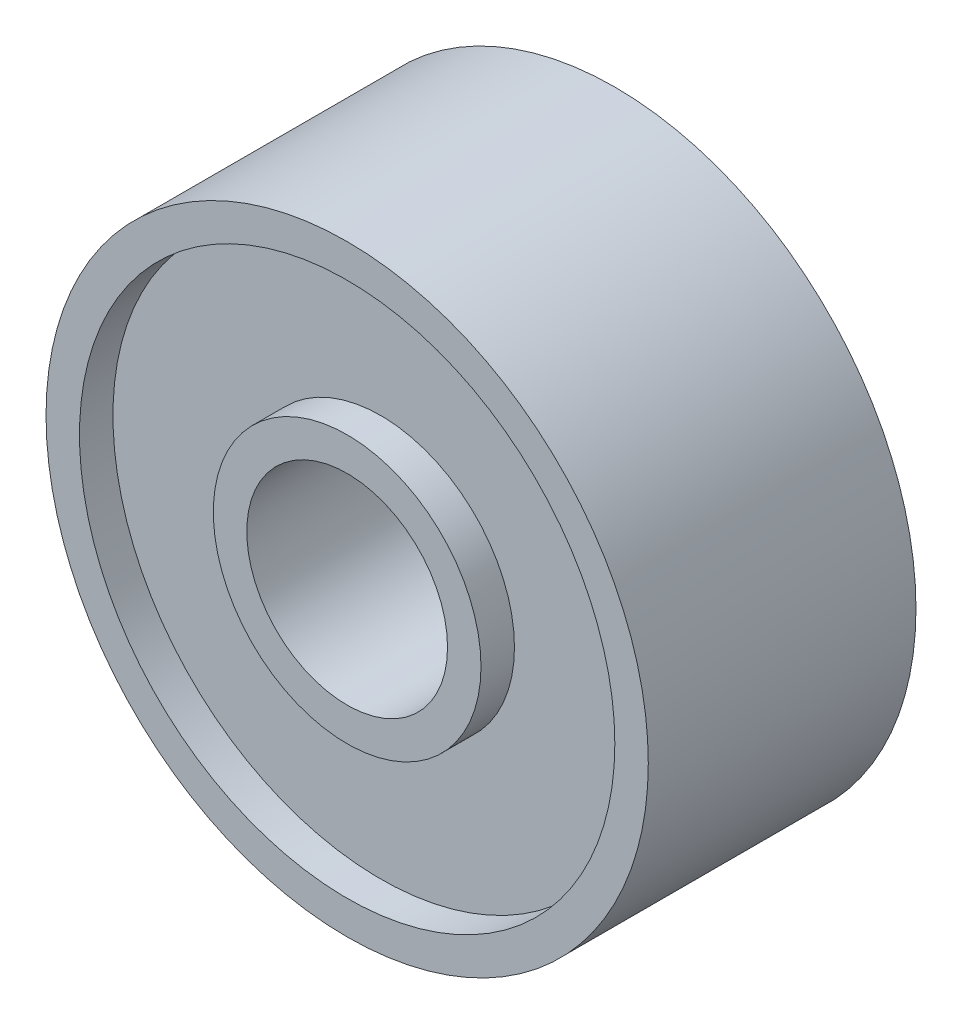
from build123d import *

# Parameters (mm, degrees)
SKETCH_1_R          = 4.5
EXTRUDE_1_DEPTH     = 2
SKETCH_2_R          = 1.5
CUT_EXTRUDE_1_DEPTH = 5
SKETCH_3_R          = 4
SKETCH_3_R_2        = 2
CUT_EXTRUDE_2_DEPTH = 0.5


with BuildPart() as part:
    # 草圖1 → 填料-伸長1 (new body, symmetric)
    with BuildSketch(Plane.XY):
        Circle(SKETCH_1_R)
    extrude(amount=EXTRUDE_1_DEPTH, both=True)

    # 草圖2 → 除料-伸長1 (cut, through all)
    with BuildSketch(Plane.XY.offset(2)):
        Circle(SKETCH_2_R)
    extrude(amount=-CUT_EXTRUDE_1_DEPTH, mode=Mode.SUBTRACT)

    # 草圖3 → 除料-伸長2 (cut)
    with BuildSketch(Plane.XY.offset(2)):
        Circle(SKETCH_3_R)
        Circle(SKETCH_3_R_2, mode=Mode.SUBTRACT)
    cut_extrude_2 = extrude(amount=-CUT_EXTRUDE_2_DEPTH, mode=Mode.SUBTRACT)

    # 鏡射1: 除料-伸長2 across plane
    add(cut_extrude_2.mirror(Plane.XY), mode=Mode.SUBTRACT)


solid = part.part
